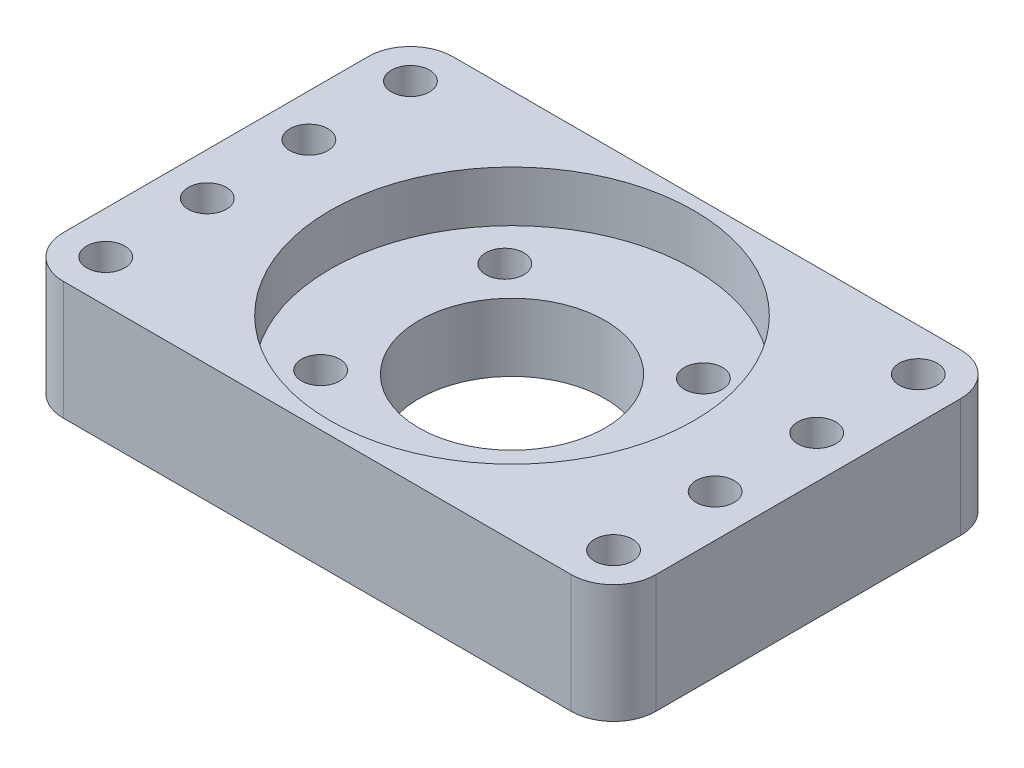
from build123d import *

# Parameters (mm, degrees)
SKETCH1_W           = 70
SKETCH1_H           = 46
SKETCH1_R           = 11
BOSS_EXTRUDE1_DEPTH = 8
SKETCH2_W           = 70
SKETCH2_H           = 46
SKETCH2_R           = 21.5
BOSS_EXTRUDE2_DEPTH = 6
SKETCH3_R           = 2.25
CUT_EXTRUDE1_DEPTH  = 9
CUT_EXTRUDE2_DEPTH  = 3.2
FILLET1_R           = 5
SKETCH6_R           = 2.25
CUT_EXTRUDE3_DEPTH  = 15


with BuildPart() as part:
    # Sketch1 → Boss-Extrude1 (new body)
    with BuildSketch(Plane(origin=(0, 0, 0), x_dir=(1, 0, 0), z_dir=(0, 1, 0))):
        Rectangle(SKETCH1_W, SKETCH1_H)
        Circle(SKETCH1_R, mode=Mode.SUBTRACT)
    extrude(amount=BOSS_EXTRUDE1_DEPTH)

    # Sketch2 → Boss-Extrude2 (add)
    with BuildSketch(Plane(origin=(0, 8, 0), x_dir=(1, 0, 0), z_dir=(0, 1, 0))):
        Rectangle(SKETCH2_W, SKETCH2_H)
        Circle(SKETCH2_R, mode=Mode.SUBTRACT)
    extrude(amount=BOSS_EXTRUDE2_DEPTH)

    # Sketch3 → Cut-Extrude1 (cut, through all)
    with BuildSketch(Plane(origin=(0, 8, 0), x_dir=(1, 0, 0), z_dir=(0, 1, 0))):
        with Locations((-11.730749234, 10.880694942)):
            Circle(SKETCH3_R)
        with Locations((11.730749234, 10.880694942)):
            Circle(SKETCH3_R)
        with Locations((11.730749234, -10.880694942)):
            Circle(SKETCH3_R)
        with Locations((-11.730749234, -10.880694942)):
            Circle(SKETCH3_R)
    extrude(amount=-CUT_EXTRUDE1_DEPTH, mode=Mode.SUBTRACT)

    # Sketch5 → Cut-Extrude2 (cut)
    with BuildSketch(Plane.XZ):
        Polygon((-12.629361921, 14.820977745), (-15.592440583, 12.072614928), (-14.693827896, 8.132332124), (-10.832136547, 6.940412138), (-7.869057884, 9.688774955), (-8.767670572, 13.629057759), align=None)
        Polygon((-10.832136547, -6.940412138), (-14.693827896, -8.132332124), (-15.592440583, -12.072614928), (-12.629361921, -14.820977745), (-8.767670572, -13.629057759), (-7.869057884, -9.688774955), align=None)
        Polygon((10.832136547, -6.940412138), (7.869057884, -9.688774955), (8.767670572, -13.629057759), (12.629361921, -14.820977745), (15.592440583, -12.072614928), (14.693827896, -8.132332124), align=None)
        Polygon((7.869057884, 9.688774955), (10.832136547, 6.940412138), (14.693827896, 8.132332124), (15.592440583, 12.072614928), (12.629361921, 14.820977745), (8.767670572, 13.629057759), align=None)
    extrude(amount=-CUT_EXTRUDE2_DEPTH, mode=Mode.SUBTRACT)

    # Fillet1
    fillet1_edges = [part.edges().sort_by_distance(p)[0] for p in [
        (35, 7, 23),
        (-35, 7, 23),
        (-35, 7, -23),
        (35, 7, -23),
    ]]
    fillet(fillet1_edges, radius=FILLET1_R)

    # Sketch6 → Cut-Extrude3 (cut, through all)
    with BuildSketch(Plane(origin=(0, 14, 0), x_dir=(1, 0, 0), z_dir=(0, 1, 0))):
        with Locations((-30, 18)):
            Circle(SKETCH6_R)
        with Locations((-30, -18)):
            Circle(SKETCH6_R)
        with Locations((30, -18)):
            Circle(SKETCH6_R)
        with Locations((30, 18)):
            Circle(SKETCH6_R)
        with Locations((-30, 6)):
            Circle(SKETCH6_R)
        with Locations((-30, -6)):
            Circle(SKETCH6_R)
        with Locations((30, -6)):
            Circle(SKETCH6_R)
        with Locations((30, 6)):
            Circle(SKETCH6_R)
    extrude(amount=-CUT_EXTRUDE3_DEPTH, mode=Mode.SUBTRACT)


solid = part.part
